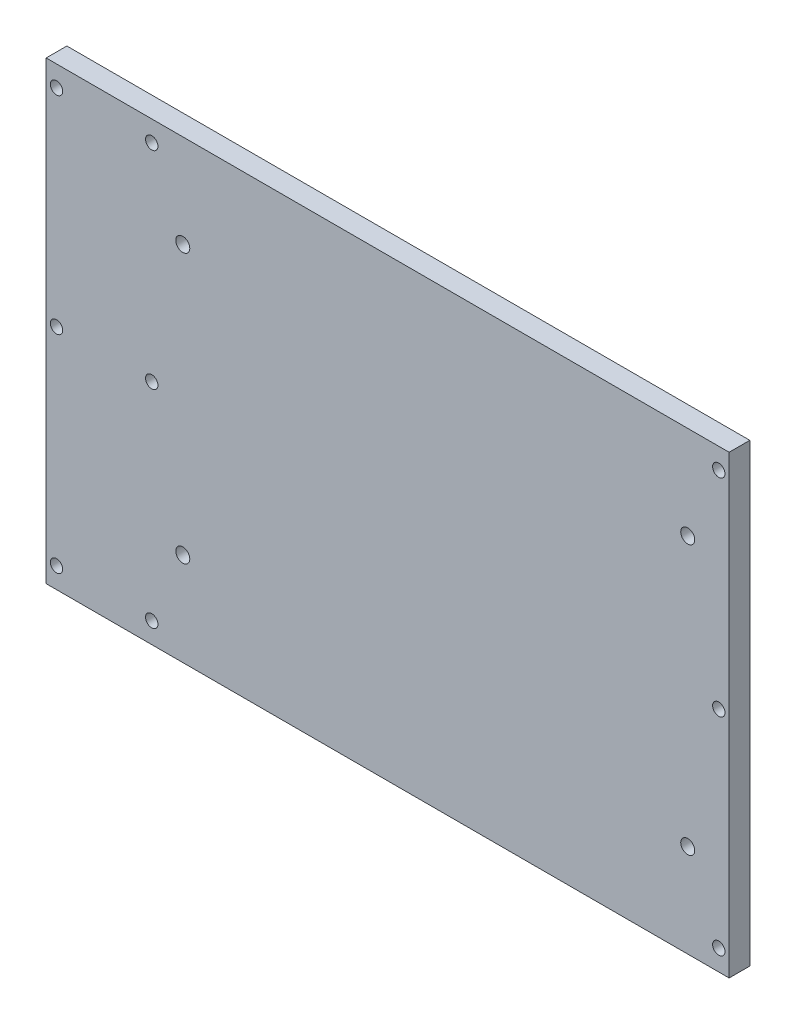
from build123d import *

# Parameters (mm, degrees)
SKETCH1_W                       = 209.55
SKETCH1_H                       = 139.7
BOSS_EXTRUDE1_DEPTH             = 3.175
F_6_CLEARANCE_HOLE1_D           = 4.3053
F_6_CLEARANCE_HOLE1_DEPTH       = 9.652
F_6_CLEARANCE_HOLE1_TIP         = 1.293442612
F_6_CLEARANCE_HOLE2_D           = 3.7973
F_6_CLEARANCE_HOLE2_CSINK_D     = 5.0673
F_6_CLEARANCE_HOLE2_CSINK_ANGLE = 90


with BuildPart() as part:
    # Sketch1 → Boss-Extrude1 (new body, symmetric)
    with BuildSketch(Plane.XY):
        Rectangle(SKETCH1_W, SKETCH1_H)
    extrude(amount=BOSS_EXTRUDE1_DEPTH, both=True)

    # #6 Clearance Hole1
    with Locations(Plane.XY.offset(3.175)):
        with Locations((-62.865, 41.275), (92.075, 41.275), (92.075, -41.275), (-62.865, -41.275)):
            Hole(F_6_CLEARANCE_HOLE1_D / 2, depth=F_6_CLEARANCE_HOLE1_DEPTH)
            with Locations((0, 0, -(F_6_CLEARANCE_HOLE1_DEPTH + F_6_CLEARANCE_HOLE1_TIP / 2))):  # 118° drill point
                Cone(0, F_6_CLEARANCE_HOLE1_D / 2, F_6_CLEARANCE_HOLE1_TIP, mode=Mode.SUBTRACT)

    # #6 Clearance Hole2 (through all)
    with Locations(Plane(origin=(0, 0, -3.175), x_dir=(-1, 0, 0), z_dir=(0, 0, -1))):
        with Locations((-101.6, 63.5), (-101.6, 0), (-101.6, -63.5), (72.39, 63.5), (72.39, 0), (72.39, -63.5), (101.6, -63.5), (101.6, 0), (101.6, 63.5)):
            CounterSinkHole(F_6_CLEARANCE_HOLE2_D / 2, F_6_CLEARANCE_HOLE2_CSINK_D / 2, counter_sink_angle=F_6_CLEARANCE_HOLE2_CSINK_ANGLE)


solid = part.part
